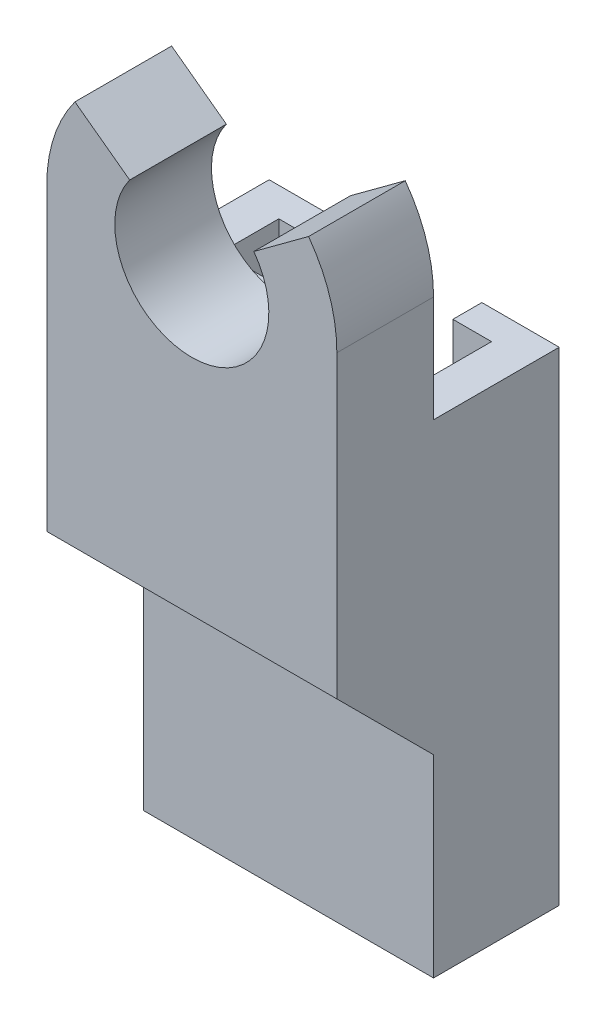
from build123d import *

# Parameters (mm, degrees)
BOSS_EXTRUDE2_DEPTH = 25
BOSS_EXTRUDE4_DEPTH = 5
BOSS_EXTRUDE5_DEPTH = 15


with BuildPart() as part:
    # Sketch1 → Boss-Extrude2 (new body)
    with BuildSketch(Plane(origin=(0, 0, 0), x_dir=(1, 0, 0), z_dir=(0, 1, 0))):
        Polygon((0, 0), (15, 0), (15, 6.5), (11, 6.5), (11, 5), (13, 5), (13, 2), (2, 2), (2, 5), (4, 5), (4, 6.5), (0, 6.5), align=None)
    extrude(amount=BOSS_EXTRUDE2_DEPTH)

    # Sketch3 → Boss-Extrude4 (add)
    with BuildSketch(Plane.XY):
        with BuildLine():
            Line((15, 25), (15, 28.291553618))
            Line((15, 28.291553618), (15, 30.5))
            ThreePointArc((15, 30.5), (14.62928544, 32.855859369), (13.53772985, 34.976238828))
            Line((13.53772985, 34.976238828), (10.707203961, 32.890364565))
            ThreePointArc((10.707203961, 32.890364565), (7.504387795, 26.542932427), (4.28759779, 32.883294263))
            Line((4.28759779, 32.883294263), (1.455694475, 34.967301819))
            ThreePointArc((1.455694475, 34.967301819), (0.3689938, 32.850585244), (0, 30.5))
            Line((0, 30.5), (0, 28.291553618))
            Line((0, 28.291553618), (0, 25))
            Line((0, 25), (0, 15))
            Line((0, 15), (15, 15))
            Line((15, 15), (15, 25))
        make_face()
    extrude(amount=BOSS_EXTRUDE4_DEPTH)

    # Sketch4 → Boss-Extrude5 (add)
    with BuildSketch(Plane(origin=(15, 0, 0), x_dir=(0, 0, -1), z_dir=(1, 0, 0))):
        Polygon((-5, 15), (0, 10), (0, 15), align=None)
    extrude(amount=-BOSS_EXTRUDE5_DEPTH)


solid = part.part
